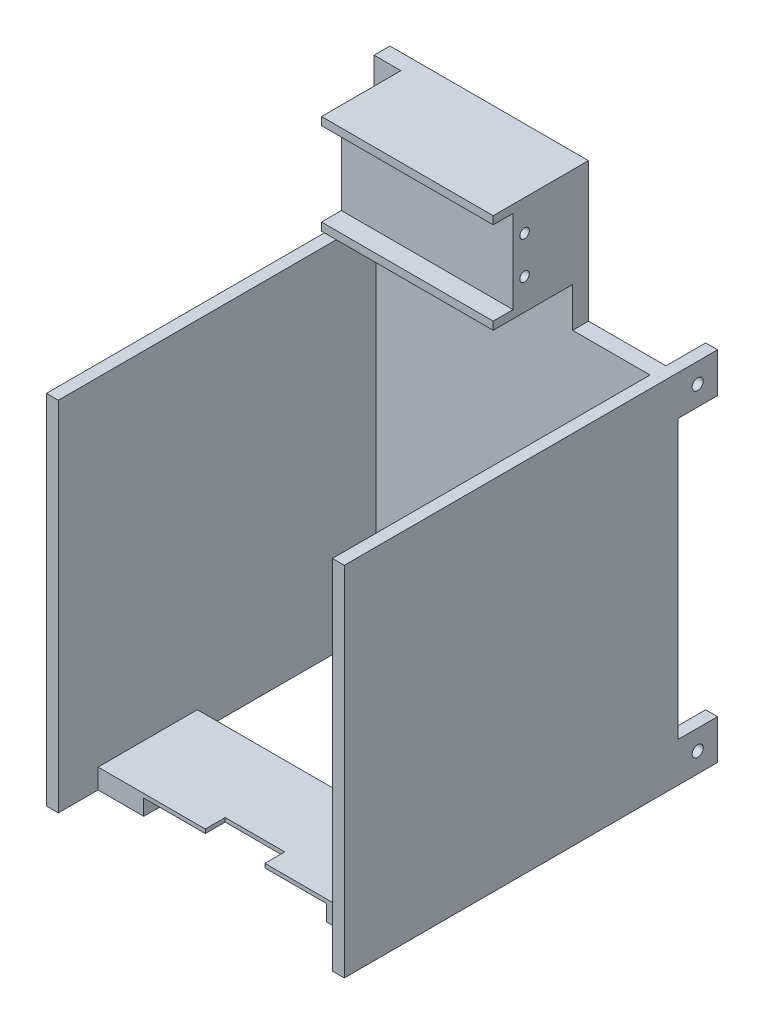
from build123d import *

# Parameters (mm, degrees)
EXTRUDE_1_DEPTH     = 4
SKETCH_3_W          = 43.235473071
SKETCH_3_H          = 2
EXTRUDE_2_DEPTH     = 20
SKETCH_4_W          = 43.235473071
SKETCH_4_H          = 21
EXTRUDE_3_DEPTH     = 15
SKETCH_8_W          = 3
SKETCH_8_H          = 10
EXTRUDE_4_DEPTH     = 10
SKETCH_10_R         = 1.4
CUT_EXTRUDE_1_DEPTH = 83
SKETCH_11_W         = 3
SKETCH_11_H         = 90
EXTRUDE_5_DEPTH     = 80
SKETCH_12_W         = 72.707770749
SKETCH_12_H         = 25
EXTRUDE_6_DEPTH     = 5
SKETCH_13_W         = 46
SKETCH_13_H         = 20
CUT_EXTRUDE_2_DEPTH = 4
CUT_EXTRUDE_3_REACH = 123
SKETCH_14_W         = 15
SKETCH_14_H         = 5
SKETCH_15_R         = 1.2
CUT_EXTRUDE_4_DEPTH = 10


with BuildPart() as part:
    # 草圖1 → 填料-伸長1 (new body)
    with BuildSketch(Plane.XY):
        Polygon((-37.5, 45), (-35, 45), (-35, 80), (15, 80), (15, 45), (37.5, 45), (37.5, -45), (-37.5, -45), align=None)
    extrude(amount=EXTRUDE_1_DEPTH)

    # 草圖3 → 填料-伸長2 (add)
    with BuildSketch(Plane.XY.offset(4)):
        with Locations((-6.617736535, 56)):
            Rectangle(SKETCH_3_W, SKETCH_3_H)
        with Locations((-6.617736535, 79)):
            Rectangle(SKETCH_3_W, SKETCH_3_H)
    extrude(amount=EXTRUDE_2_DEPTH)

    # 草圖4 → 填料-伸長3 (add)
    with BuildSketch(Plane.XY.offset(4)):
        with Locations((-6.617736535, 67.5)):
            Rectangle(SKETCH_4_W, SKETCH_4_H)
    extrude(amount=EXTRUDE_3_DEPTH)

    # 草圖8 → 填料-伸長4 (add)
    with BuildSketch(Plane(origin=(0, 0, 0), x_dir=(-1, 0, 0), z_dir=(0, 0, -1))):
        with Locations((-36, 40)):
            Rectangle(SKETCH_8_W, SKETCH_8_H)
        with Locations((36, 40)):
            Rectangle(SKETCH_8_W, SKETCH_8_H)
        with Locations((36, -40)):
            Rectangle(SKETCH_8_W, SKETCH_8_H)
        with Locations((-36, -40)):
            Rectangle(SKETCH_8_W, SKETCH_8_H)
    extrude(amount=EXTRUDE_4_DEPTH)

    # 草圖10 → 除料-伸長1 (cut)
    with BuildSketch(Plane(origin=(37.5, 0, 0), x_dir=(0, 0, -1), z_dir=(1, 0, 0))):
        with Locations((5, 40)):
            Circle(SKETCH_10_R)
        with Locations((5, -40)):
            Circle(SKETCH_10_R)
    extrude(amount=-CUT_EXTRUDE_1_DEPTH, mode=Mode.SUBTRACT)

    # 草圖11 → 填料-伸長5 (add)
    with BuildSketch(Plane.XY.offset(4)):
        with Locations((-36, 0)):
            Rectangle(SKETCH_11_W, SKETCH_11_H)
        with Locations((36, 0)):
            Rectangle(SKETCH_11_W, SKETCH_11_H)
    extrude(amount=EXTRUDE_5_DEPTH)

    # 草圖12 → 填料-伸長6 (add)
    with BuildSketch(Plane.XZ.offset(45)):
        with Locations((0.126228768, 61.5)):
            Rectangle(SKETCH_12_W, SKETCH_12_H)
    extrude(amount=-EXTRUDE_6_DEPTH)

    # 草圖13 → 除料-伸長2 (cut)
    with BuildSketch(Plane.XZ.offset(45)):
        with Locations((0, 64)):
            Rectangle(SKETCH_13_W, SKETCH_13_H)
    extrude(amount=-CUT_EXTRUDE_2_DEPTH, mode=Mode.SUBTRACT)

    # 草圖14 → 除料-伸長3 (cut, up to next)
    with BuildSketch(Plane.XZ.offset(41), mode=Mode.PRIVATE) as cut_extrude_3_sk1:
        with Locations((0, 71.5)):
            Rectangle(SKETCH_14_W, SKETCH_14_H)
    cut_extrude_3_tool1 = extrude(cut_extrude_3_sk1.sketch, amount=-CUT_EXTRUDE_3_REACH, mode=Mode.PRIVATE) & part.part
    add(cut_extrude_3_tool1.solids().sort_by_distance((0, -41, 71.5))[0], mode=Mode.SUBTRACT)

    # 草圖15 → 除料-伸長4 (cut)
    with BuildSketch(Plane(origin=(15, 0, 0), x_dir=(0, 0, -1), z_dir=(1, 0, 0))):
        with Locations((-16.1, 72.2)):
            Circle(SKETCH_15_R)
        with Locations((-16.1, 62.8)):
            Circle(SKETCH_15_R)
    extrude(amount=-CUT_EXTRUDE_4_DEPTH, mode=Mode.SUBTRACT)


solid = part.part
